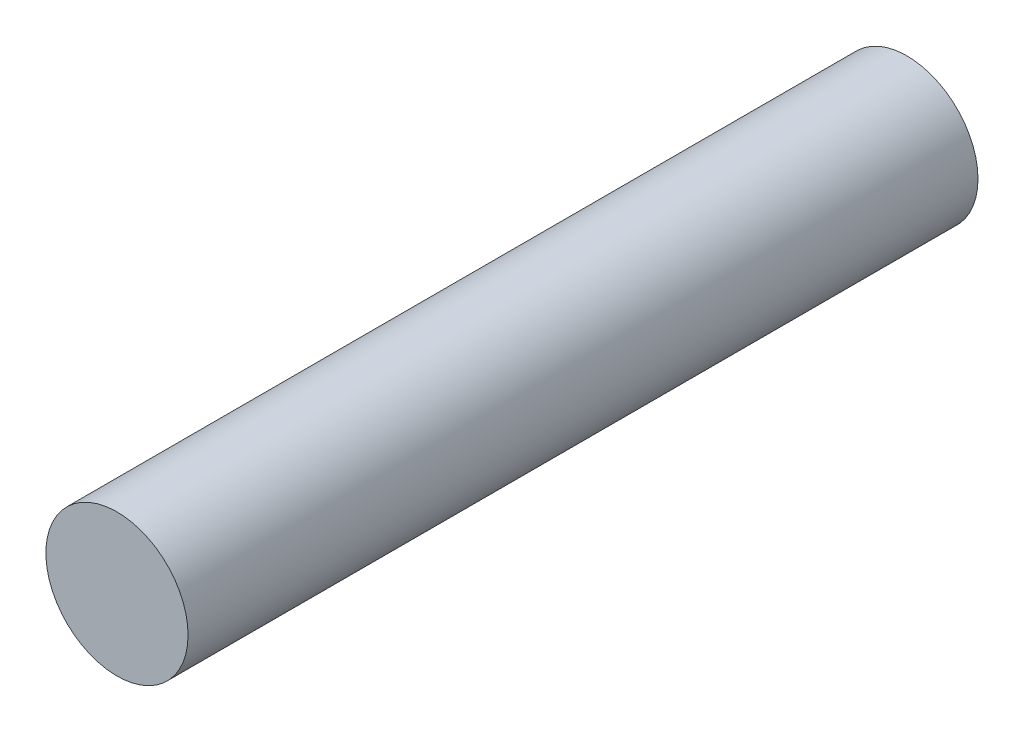
from build123d import *

# Parameters (mm, degrees)
SKETCH1_R           = 1.35
BOSS_EXTRUDE1_DEPTH = 15


with BuildPart() as part:
    # Sketch1 → Boss-Extrude1 (new body)
    with BuildSketch(Plane.XY):
        Circle(SKETCH1_R)
    extrude(amount=BOSS_EXTRUDE1_DEPTH)


solid = part.part
